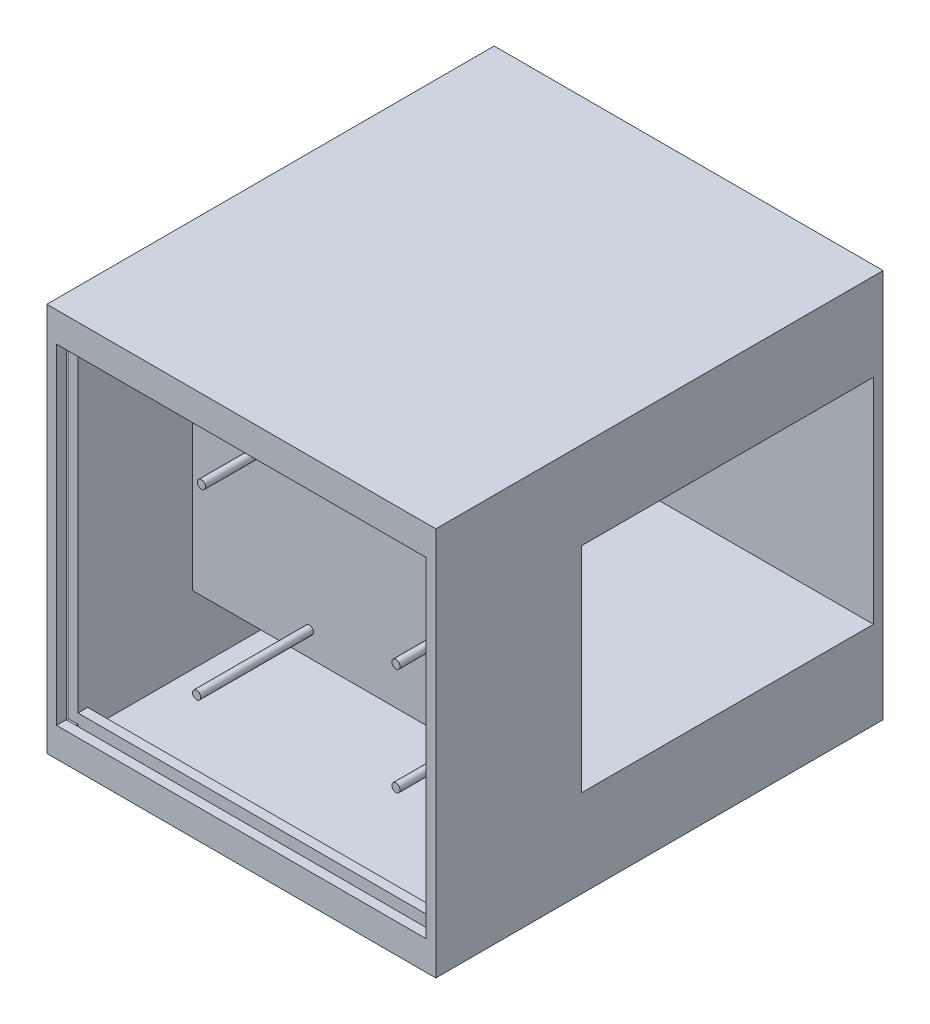
from build123d import *

# Parameters (mm, degrees)
SKETCH1_W           = 101.6
SKETCH1_H           = 101.6
BOSS_EXTRUDE2_DEPTH = 116.84
SKETCH2_W           = 76.2
SKETCH2_H           = 55.88
CUT_EXTRUDE1_DEPTH  = 99.06
SKETCH3_W           = 111.76
SKETCH3_H           = 17.78
CUT_EXTRUDE2_DEPTH  = 96.52
SKETCH4_W           = 96.52
SKETCH4_H           = 96.52
CUT_EXTRUDE3_DEPTH  = 35.56
SKETCH5_R           = 1.0795
BOSS_EXTRUDE3_DEPTH = 29.464
SKETCH8_W           = 3.048
SKETCH8_H           = 91.44
CUT_EXTRUDE4_DEPTH  = 2.54
SKETCH10_W          = 2.54
SKETCH10_H          = 5.08
SKETCH10_H_2        = 5.198880867
BOSS_EXTRUDE4_DEPTH = 96.52


with BuildPart() as part:
    # Sketch1 → Boss-Extrude2 (new body)
    with BuildSketch(Plane.XY):
        with Locations((50.8, -50.8)):
            Rectangle(SKETCH1_W, SKETCH1_H)
    extrude(amount=BOSS_EXTRUDE2_DEPTH)

    # Sketch2 → Cut-Extrude1 (cut)
    with BuildSketch(Plane(origin=(101.6, 0, 0), x_dir=(0, 0, -1), z_dir=(1, 0, 0))):
        with Locations((-40.64, -50.8)):
            Rectangle(SKETCH2_W, SKETCH2_H)
    extrude(amount=-CUT_EXTRUDE1_DEPTH, mode=Mode.SUBTRACT)

    # Sketch3 → Cut-Extrude2 (cut)
    with BuildSketch(Plane(origin=(99.06, 0, 0), x_dir=(0, 0, -1), z_dir=(1, 0, 0))):
        with Locations((-58.42, -90.17)):
            Rectangle(SKETCH3_W, SKETCH3_H)
        with Locations((-58.42, -11.43)):
            Rectangle(SKETCH3_W, SKETCH3_H)
    extrude(amount=-CUT_EXTRUDE2_DEPTH, mode=Mode.SUBTRACT)

    # Sketch4 → Cut-Extrude3 (cut)
    with BuildSketch(Plane.XY.offset(116.84)):
        with Locations((50.8, -50.8)):
            Rectangle(SKETCH4_W, SKETCH4_H)
    extrude(amount=-CUT_EXTRUDE3_DEPTH, mode=Mode.SUBTRACT)

    # Sketch5 → Boss-Extrude3 (add)
    with BuildSketch(Plane.XY.offset(81.28)):
        with Locations((85.09, -41.91)):
            Circle(SKETCH5_R)
        with Locations((85.09, -69.85)):
            Circle(SKETCH5_R)
        with Locations((34.29, -26.67)):
            Circle(SKETCH5_R)
        with Locations((33.02, -74.93)):
            Circle(SKETCH5_R)
    extrude(amount=BOSS_EXTRUDE3_DEPTH)

    # Sketch8 → Cut-Extrude4 (cut)
    with BuildSketch(Plane.ZY):
        with Locations((112.776, -50.8)):
            Rectangle(SKETCH8_W, SKETCH8_H)
    extrude(amount=-CUT_EXTRUDE4_DEPTH, mode=Mode.SUBTRACT)

    # Sketch10 → Boss-Extrude4 (add)
    with BuildSketch(Plane(origin=(2.54, 0, 0), x_dir=(0, 0, -1), z_dir=(1, 0, 0))):
        with Locations((-115.57, -96.52)):
            Rectangle(SKETCH10_W, SKETCH10_H)
        with Locations((-109.982, -96.52)):
            Rectangle(SKETCH10_W, SKETCH10_H)
        with Locations((-115.57, -5.139440434)):
            Rectangle(SKETCH10_W, SKETCH10_H_2)
        with Locations((-109.982, -5.08)):
            Rectangle(SKETCH10_W, SKETCH10_H)
    extrude(amount=BOSS_EXTRUDE4_DEPTH)


solid = part.part
